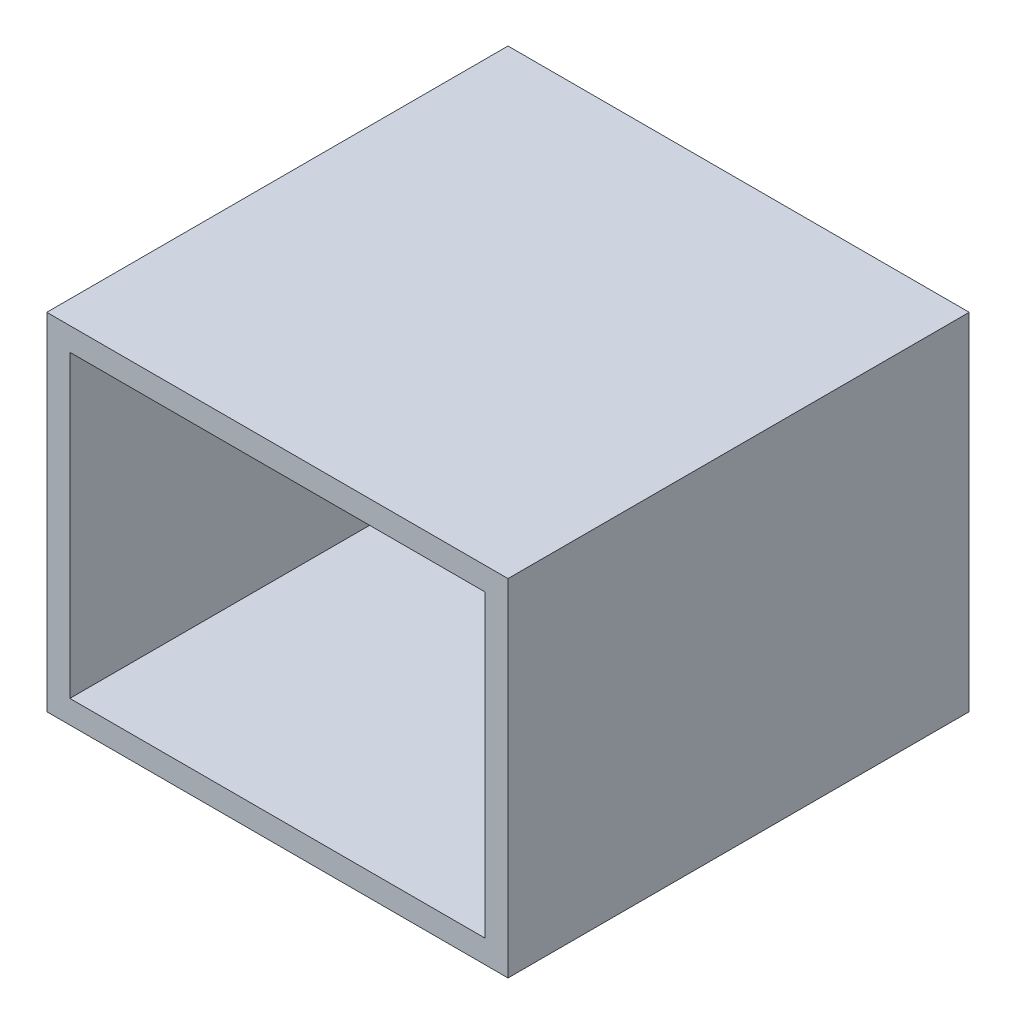
from build123d import *

# Parameters (mm, degrees)
ESQUISSE1_W        = 200
ESQUISSE1_H        = 150
ESQUISSE1_W_2      = 180
ESQUISSE1_H_2      = 130
BOSS_EXTRU_1_DEPTH = 200


with BuildPart() as part:
    # Esquisse1 → Boss.-Extru.1 (new body)
    with BuildSketch(Plane.XY):
        with Locations((100, 75)):
            Rectangle(ESQUISSE1_W, ESQUISSE1_H)
        with Locations((100, 75)):
            Rectangle(ESQUISSE1_W_2, ESQUISSE1_H_2, mode=Mode.SUBTRACT)
    extrude(amount=BOSS_EXTRU_1_DEPTH)


solid = part.part
